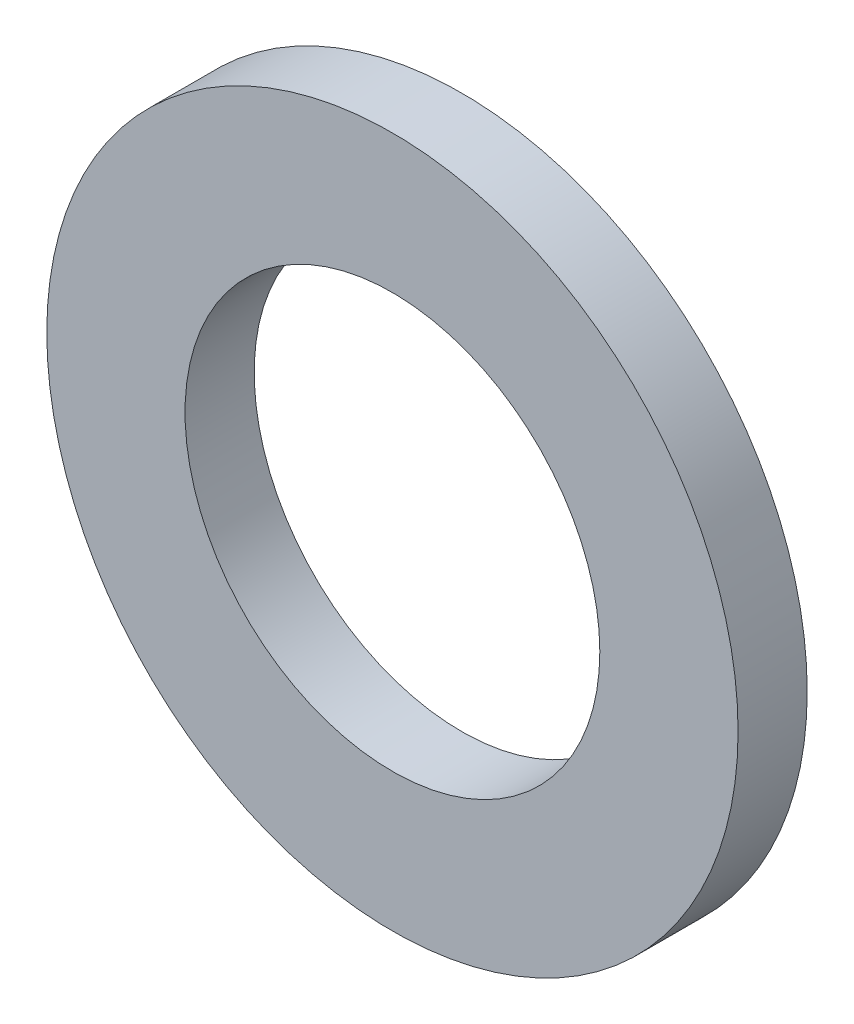
from build123d import *

# Parameters (mm, degrees)
SKETCH1_R           = 7.9375
SKETCH1_R_2         = 4.7625
BOSS_EXTRUDE1_DEPTH = 1.5875


with BuildPart() as part:
    # Sketch1 → Boss-Extrude1 (new body)
    with BuildSketch(Plane.XY):
        Circle(SKETCH1_R)
        Circle(SKETCH1_R_2, mode=Mode.SUBTRACT)
    extrude(amount=BOSS_EXTRUDE1_DEPTH)


solid = part.part
